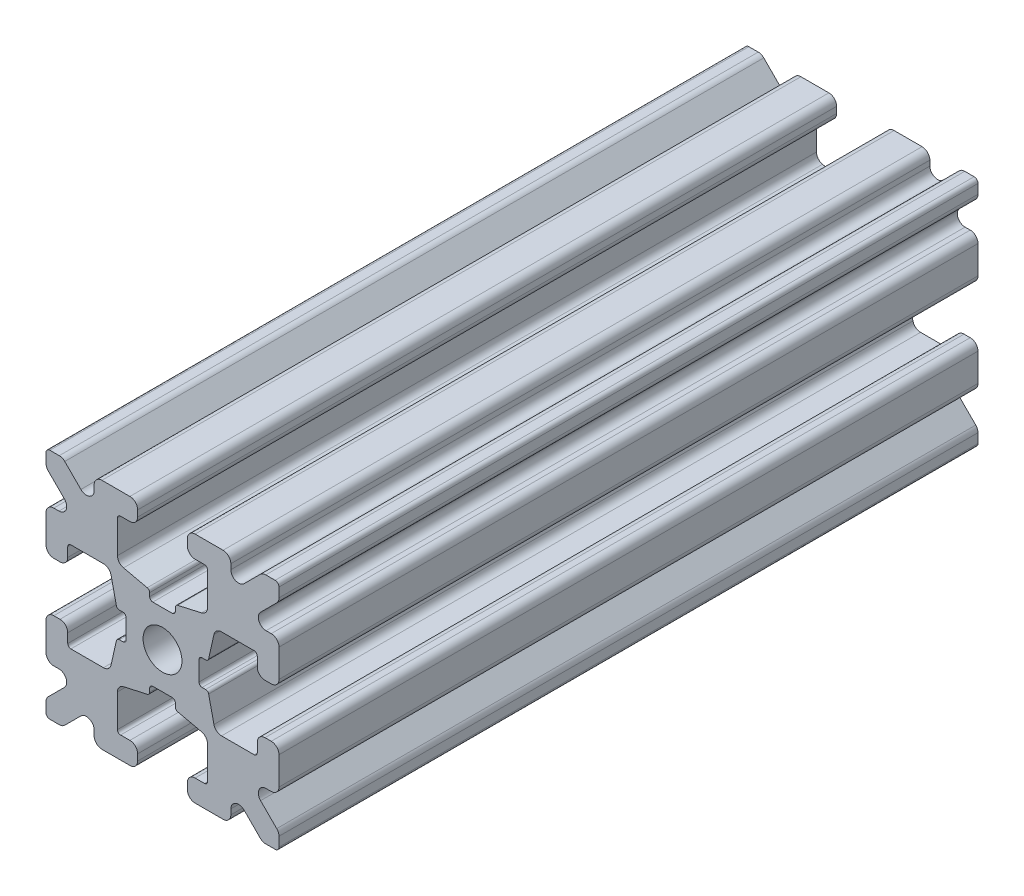
from build123d import *

# Parameters (mm, degrees)
SKETCH1_W           = 15
SKETCH1_H           = 15
SKETCH1_R           = 1.25
BOSS_EXTRUDE1_DEPTH = 22.5
FILLET1_R           = 0.25
CUT_EXTRUDE1_DEPTH  = 46
CUT_EXTRUDE3_DEPTH  = 46
FILLET3_R           = 0.5
FILLET4_R           = 0.5
FILLET5_R           = 3
FILLET6_R           = 0.2
CUT_EXTRUDE4_DEPTH  = 46
FILLET8_R           = 0.5
SKETCH6_W           = 5.1529354
SKETCH6_H           = 1.651
SKETCH6_W_2         = 1.651
SKETCH6_H_2         = 5.1529354
CUT_EXTRUDE5_DEPTH  = 46
FILLET10_R          = 0.2


with BuildPart() as part:
    # Sketch1 → Boss-Extrude1 (new body, symmetric)
    with BuildSketch(Plane.XY):
        Rectangle(SKETCH1_W, SKETCH1_H)
        Circle(SKETCH1_R, mode=Mode.SUBTRACT)
    extrude(amount=BOSS_EXTRUDE1_DEPTH, both=True)

    # Fillet1
    fillet1_edges = [part.edges().sort_by_distance(p)[0] for p in [
        (7.5, -7.5, 0),
        (-7.5, -7.5, 0),
        (-7.5, 7.5, 0),
        (7.5, 7.5, 0),
    ]]
    fillet(fillet1_edges, radius=FILLET1_R)

    # Sketch2 → Cut-Extrude1 (cut, through all)
    with BuildSketch(Plane.XY.offset(22.5)):
        Polygon((-7.5, 1.6), (-6.1, 1.6), (-6.1, 2.9), (-3.4, 2.9), (-3.4, -2.9), (-6.1, -2.9), (-6.1, -1.6), (-7.5, -1.6), align=None)
        Polygon((2.9, 6.1), (1.6, 6.1), (1.6, 7.5), (-1.6, 7.5), (-1.6, 6.1), (-2.9, 6.1), (-2.9, 3.4), (2.9, 3.4), align=None)
        Polygon((-1.6, -7.5), (-1.6, -6.1), (-2.9, -6.1), (-2.9, -3.4), (2.9, -3.4), (2.9, -6.1), (1.6, -6.1), (1.6, -7.5), align=None)
        Polygon((6.1, -2.9), (6.1, -1.6), (7.5, -1.6), (7.5, 1.6), (6.1, 1.6), (6.1, 2.9), (3.4, 2.9), (3.4, -2.9), align=None)
    extrude(amount=-CUT_EXTRUDE1_DEPTH, mode=Mode.SUBTRACT)

    # Sketch4 → Cut-Extrude3 (cut, through all)
    with BuildSketch(Plane.XY.offset(22.5)):
        Polygon((-3.4, 2.9), (-2.75, 0), (-3.4, -2.9), align=None)
        Polygon((-2.9, 3.4), (0, 2.75), (2.9, 3.4), align=None)
        Polygon((3.4, 2.9), (2.75, 0), (3.4, -2.9), align=None)
        Polygon((-2.9, -3.4), (0, -2.75), (2.9, -3.4), align=None)
    extrude(amount=-CUT_EXTRUDE3_DEPTH, mode=Mode.SUBTRACT)

    # Fillet3
    fillet3_edges = [part.edges().sort_by_distance(p)[0] for p in [
        (1.6, -7.5, 0),
        (-1.6, -7.5, 0),
        (-1.6, -6.1, 0),
        (1.6, -6.1, 0),
        (6.1, 1.6, 0),
        (7.5, 1.6, 0),
        (7.5, -1.6, 0),
        (6.1, -1.6, 0),
        (-7.5, -1.6, 0),
        (-7.5, 1.6, 0),
        (-6.1, 1.6, 0),
        (-6.1, -1.6, 0),
        (-1.6, 6.1, 0),
        (-1.6, 7.5, 0),
        (1.6, 7.5, 0),
        (1.6, 6.1, 0),
    ]]
    fillet(fillet3_edges, radius=FILLET3_R)

    # Fillet4
    fillet4_edges = [part.edges().sort_by_distance(p)[0] for p in [
        (-2.9, -3.4, 0),
        (2.9, -3.4, 0),
        (3.4, -2.9, 0),
        (3.4, 2.9, 0),
        (-3.4, 2.9, 0),
        (-3.4, -2.9, 0),
        (2.9, 3.4, 0),
        (-2.9, 3.4, 0),
    ]]
    fillet(fillet4_edges, radius=FILLET4_R)

    # Fillet5
    fillet5_edges = [part.edges().sort_by_distance(p)[0] for p in [
        (-2.75, 0, 0),
        (0, 2.75, 0),
        (2.75, 0, 0),
        (0, -2.75, 0),
    ]]
    fillet(fillet5_edges, radius=FILLET5_R)

    # Fillet6
    fillet6_edges = [part.edges().sort_by_distance(p)[0] for p in [
        (-2.9, -6.1, 0),
        (2.9, -6.1, 0),
        (6.1, -2.9, 0),
        (6.1, 2.9, 0),
        (-6.1, 2.9, 0),
        (-6.1, -2.9, 0),
        (2.9, 6.1, 0),
        (-2.9, 6.1, 0),
    ]]
    fillet(fillet6_edges, radius=FILLET6_R)

    # Sketch5 → Cut-Extrude4 (cut, through all)
    with BuildSketch(Plane.XY.offset(22.5)):
        Polygon((-7.5, 6.439339828), (-5.460660172, 4.4), (-7.5, 4.4), align=None)
        Polygon((-6.439339828, 7.5), (-4.4, 5.460660172), (-4.4, 7.5), align=None)
        Polygon((4.4, 7.5), (6.439339828, 7.5), (4.4, 5.460660172), align=None)
        Polygon((7.5, 6.439339828), (7.5, 4.4), (5.460660172, 4.4), align=None)
        Polygon((7.5, -6.439339828), (5.460660172, -4.4), (7.5, -4.4), align=None)
        Polygon((6.439339828, -7.5), (4.4, -5.460660172), (4.4, -7.5), align=None)
        Polygon((-4.4, -7.5), (-6.439339828, -7.5), (-4.4, -5.460660172), align=None)
        Polygon((-7.5, -6.439339828), (-7.5, -4.4), (-5.460660172, -4.4), align=None)
    extrude(amount=-CUT_EXTRUDE4_DEPTH, mode=Mode.SUBTRACT)

    # Fillet8
    fillet8_edges = [part.edges().sort_by_distance(p)[0] for p in [
        (-7.5, 4.4, 0),
        (-7.5, 6.439339828, 0),
        (-5.460660172, 4.4, 0),
        (7.5, -4.4, 0),
        (7.5, -6.439339828, 0),
        (5.460660172, -4.4, 0),
        (5.460660172, 4.4, 0),
        (7.5, 6.439339828, 0),
        (7.5, 4.4, 0),
        (-4.4, 7.5, 0),
        (-4.4, 5.460660172, 0),
        (-6.439339828, 7.5, 0),
        (-5.460660172, -4.4, 0),
        (-7.5, -6.439339828, 0),
        (-7.5, -4.4, 0),
        (4.4, 5.460660172, 0),
        (4.4, 7.5, 0),
        (6.439339828, 7.5, 0),
        (6.439339828, -7.5, 0),
        (4.4, -7.5, 0),
        (4.4, -5.460660172, 0),
        (-6.439339828, -7.5, 0),
        (-4.4, -5.460660172, 0),
        (-4.4, -7.5, 0),
    ]]
    fillet(fillet8_edges, radius=FILLET8_R)

    # Sketch6 → Cut-Extrude5 (cut, through all)
    with BuildSketch(Plane.XY.offset(22.5)):
        with Locations((4.9235323, 0)):
            Rectangle(SKETCH6_W, SKETCH6_H)
        with Locations((0, -4.9235323)):
            Rectangle(SKETCH6_W_2, SKETCH6_H_2)
        with Locations((-4.9235323, 0)):
            Rectangle(SKETCH6_W, SKETCH6_H)
        with Locations((0, 4.9235323)):
            Rectangle(SKETCH6_W_2, SKETCH6_H_2)
    extrude(amount=-CUT_EXTRUDE5_DEPTH, mode=Mode.SUBTRACT)

    # Fillet10
    fillet10_edges = [part.edges().sort_by_distance(p)[0] for p in [
        (0.8255, -2.935025862, 0),
        (-0.8255, -2.935025862, 0),
        (0.8255, -2.3470646, 0),
        (-0.8255, -2.3470646, 0),
        (2.935025862, 0.8255, 0),
        (2.935025862, -0.8255, 0),
        (2.3470646, 0.8255, 0),
        (2.3470646, -0.8255, 0),
        (-2.935025862, -0.8255, 0),
        (-2.935025862, 0.8255, 0),
        (-2.3470646, -0.8255, 0),
        (-2.3470646, 0.8255, 0),
        (-0.8255, 2.935025862, 0),
        (0.8255, 2.935025862, 0),
        (-0.8255, 2.3470646, 0),
        (0.8255, 2.3470646, 0),
    ]]
    fillet(fillet10_edges, radius=FILLET10_R)


solid = part.part
